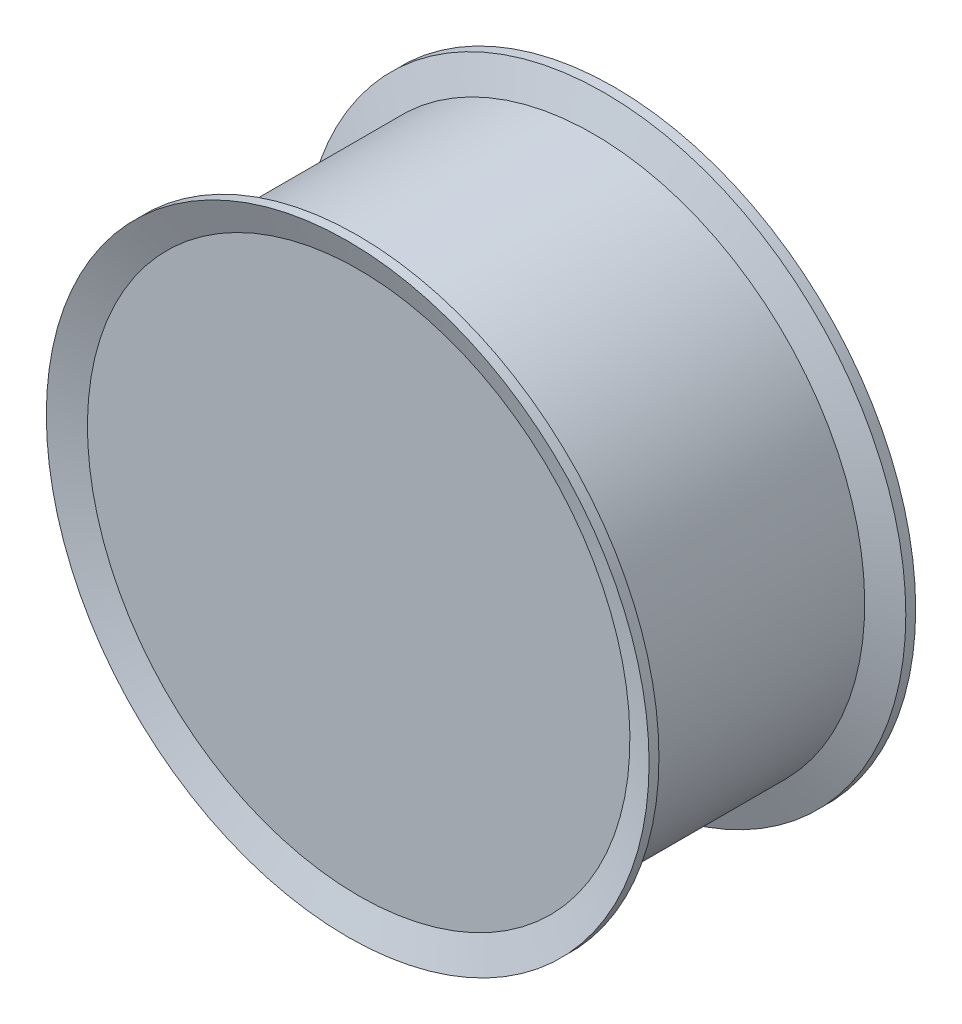
from build123d import *


with BuildPart() as part:
    # Sketch1 → Revolve1 (revolve)
    with BuildSketch(Plane(origin=(0, 0, 0), x_dir=(0, 0, -1), z_dir=(1, 0, 0))):
        Polygon((-52.768386955, 117), (-57.5, 130), (-53.24328891, 130), (-48.511675865, 117), (48.511675865, 117), (53.24328891, 130), (57.5, 130), (52.768386955, 117), (52.768386955, 0), (-52.768386955, 0), align=None)
    revolve(axis=Axis((0, 0, 52.768386955), (0, 0, -1)))


solid = part.part
